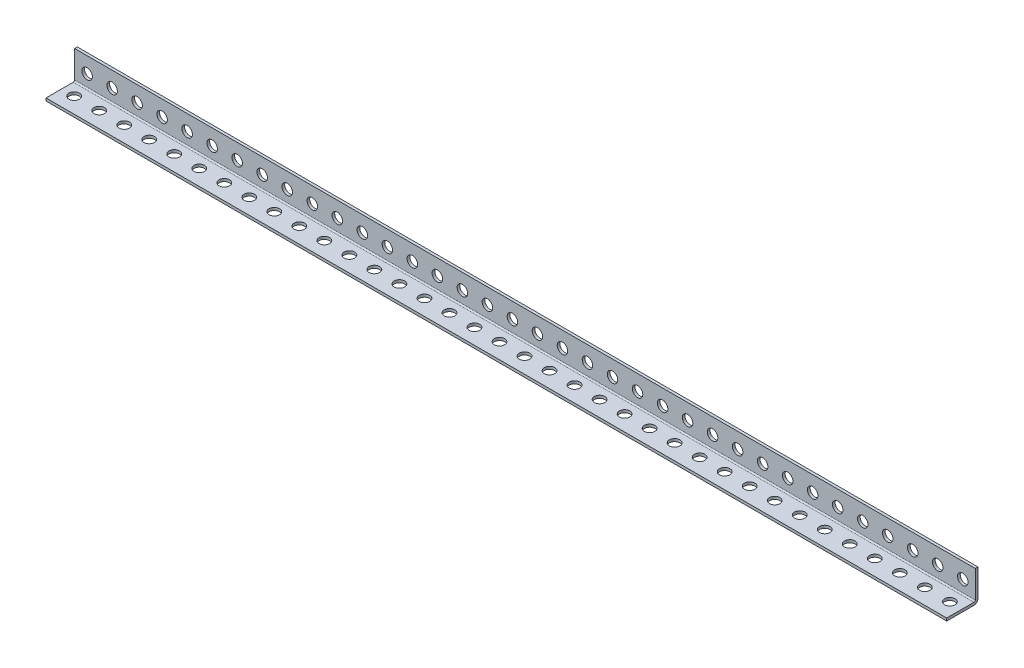
from build123d import *

# Parameters (mm, degrees)
BOSS_EXTRUDE1_DEPTH      = 457.2
BOSS_EXTRUDE1_DEPTH_BACK = 457.2
SKETCH5_R                = 5.334
CUT_EXTRUDE1_DEPTH       = 16.875
SKETCH6_R                = 5.334
CUT_EXTRUDE2_DEPTH       = 16.875
LPATTERN1_COUNT          = 36
LPATTERN1_PITCH          = 25.4


with BuildPart() as part:
    # Sketch4 → Boss-Extrude1 (new body, two sides)
    with BuildSketch(Plane(origin=(0, 0, 0), x_dir=(0, 0, -1), z_dir=(1, 0, 0))) as boss_extrude1_sk:
        with BuildLine():
            Line((-15.875, -13.1318), (11.7602, -13.1318))
            ThreePointArc((11.7602, -13.1318), (12.730067661, -12.730067661), (13.1318, -11.7602))
            Line((13.1318, -11.7602), (13.1318, 15.875))
            Line((13.1318, 15.875), (15.875, 15.875))
            Line((15.875, 15.875), (15.875, -11.7602))
            ThreePointArc((15.875, -11.7602), (14.669802983, -14.669802983), (11.7602, -15.875))
            Line((11.7602, -15.875), (-15.875, -15.875))
            Line((-15.875, -15.875), (-15.875, -13.1318))
        make_face()
    extrude(amount=BOSS_EXTRUDE1_DEPTH)
    extrude(boss_extrude1_sk.sketch, amount=-BOSS_EXTRUDE1_DEPTH_BACK)

    # Sketch5 → Cut-Extrude1 (cut, through all)
    with BuildSketch(Plane.XY):
        with Locations((444.5, 0)):
            Circle(SKETCH5_R)
    cut_extrude1 = extrude(amount=-CUT_EXTRUDE1_DEPTH, mode=Mode.SUBTRACT)

    # Sketch6 → Cut-Extrude2 (cut, through all)
    with BuildSketch(Plane(origin=(0, 0, 0), x_dir=(1, 0, 0), z_dir=(0, 1, 0))):
        with Locations((444.5, 0)):
            Circle(SKETCH6_R)
    cut_extrude2 = extrude(amount=-CUT_EXTRUDE2_DEPTH, mode=Mode.SUBTRACT)

    # LPattern1: Cut-Extrude1, Cut-Extrude2 ×36
    with Locations(*[(-i * LPATTERN1_PITCH, 0, 0) for i in range(1, LPATTERN1_COUNT)]):
        add(cut_extrude1, mode=Mode.SUBTRACT)
        add(cut_extrude2, mode=Mode.SUBTRACT)


solid = part.part
